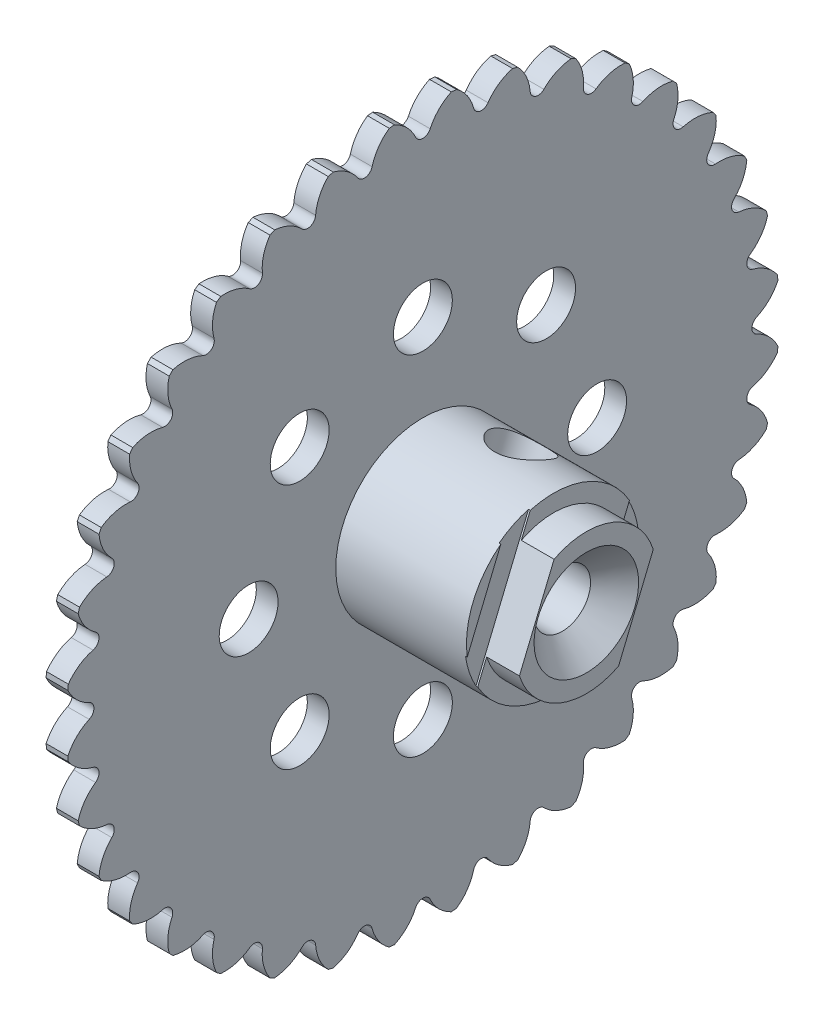
from build123d import *

# Parameters (mm, degrees)
SKETCH1_R           = 25.9588
BOSS_EXTRUDE1_DEPTH = 1.5875
SKETCH2_R           = 2.1463
CUT_EXTRUDE1_DEPTH  = 1.5875
CIRPATTERN1_COUNT   = 8
CUT_EXTRUDE2_DEPTH  = 1.5875
CIRPATTERN2_COUNT   = 36
SKETCH7_R           = 6.35
BOSS_EXTRUDE3_DEPTH = 9.525
BOSS_EXTRUDE4_DEPTH = 2.3876
SKETCH9_R           = 2.0574
CUT_EXTRUDE3_DEPTH  = 14.5001
CUT_EXTRUDE4_DEPTH  = 0.127
SKETCH12_W          = 1.984375
SKETCH12_H          = 12.7


with BuildPart() as part:
    # Sketch1 → Boss-Extrude1 (new body)
    with BuildSketch(Plane(origin=(0, 0, 0), x_dir=(0, 0, -1), z_dir=(1, 0, 0))):
        Circle(SKETCH1_R)
    extrude(amount=BOSS_EXTRUDE1_DEPTH)

    # Sketch2 → Cut-Extrude1 (cut)
    with BuildSketch(Plane(origin=(1.5875, 0, 0), x_dir=(0, 0, -1), z_dir=(1, 0, 0))):
        with Locations((0, 12.7)):
            Circle(SKETCH2_R)
    cut_extrude1 = extrude(amount=-CUT_EXTRUDE1_DEPTH, mode=Mode.SUBTRACT)

    # CirPattern1: Cut-Extrude1 ×8 about axis
    cirpattern1_axis = Axis((0, 0, 0), (1, 0, 0))
    for i in range(1, CIRPATTERN1_COUNT):
        add(cut_extrude1.rotate(cirpattern1_axis, i * 360 / CIRPATTERN1_COUNT), mode=Mode.SUBTRACT)

    # Sketch4 → Cut-Extrude2 (cut)
    with BuildSketch(Plane(origin=(1.5875, 0, 0), x_dir=(0, 0, -1), z_dir=(1, 0, 0))):
        with BuildLine():
            ThreePointArc((2.072622482, 25.875925751), (0, 25.9588), (-2.072622482, 25.875925751))
            ThreePointArc((-2.072622482, 25.875925751), (-1.163537989, 25.234699648), (-0.531460116, 24.319230865))
            ThreePointArc((-0.531460116, 24.319230865), (0, 23.9776), (0.531460116, 24.319230865))
            ThreePointArc((0.531460116, 24.319230865), (1.163537989, 25.234699648), (2.072622482, 25.875925751))
        make_face()
    cut_extrude2 = extrude(amount=-CUT_EXTRUDE2_DEPTH, mode=Mode.SUBTRACT)

    # CirPattern2: Cut-Extrude2 ×36 about axis
    cirpattern2_axis = Axis((0, 0, 0), (1, 0, 0))
    for i in range(1, CIRPATTERN2_COUNT):
        add(cut_extrude2.rotate(cirpattern2_axis, i * 360 / CIRPATTERN2_COUNT), mode=Mode.SUBTRACT)

    # Sketch7 → Boss-Extrude3 (add)
    with BuildSketch(Plane(origin=(1.5875, 0, 0), x_dir=(0, 0, -1), z_dir=(1, 0, 0))):
        Circle(SKETCH7_R)
    extrude(amount=BOSS_EXTRUDE3_DEPTH)

    # Sketch8 → Boss-Extrude4 (add)
    with BuildSketch(Plane(origin=(11.1125, 0, 0), x_dir=(0, 0, -1), z_dir=(1, 0, 0))):
        with BuildLine():
            Line((-4.876953722, -1.552504431), (-2.350740637, 4.546313459))
            ThreePointArc((-2.350740637, 4.546313459), (1.958612075, 4.728507835), (4.876953722, 1.552504431))
            Line((4.876953722, 1.552504431), (2.350740637, -4.546313459))
            ThreePointArc((2.350740637, -4.546313459), (-1.958612075, -4.728507835), (-4.876953722, -1.552504431))
        make_face()
    extrude(amount=BOSS_EXTRUDE4_DEPTH)

    # Sketch9 → Cut-Extrude3 (cut, through all)
    with BuildSketch(Plane(origin=(13.5001, 0, 0), x_dir=(0, 0, -1), z_dir=(1, 0, 0))):
        Circle(SKETCH9_R)
    extrude(amount=-CUT_EXTRUDE3_DEPTH, mode=Mode.SUBTRACT)

    # Sketch10 → Cut-Extrude4 (cut)
    with BuildSketch(Plane(origin=(11.1125, 0, 0), x_dir=(0, 0, -1), z_dir=(1, 0, 0))):
        with BuildLine():
            Line((-5.528101678, -3.124514657), (-1.699592681, 6.118323685))
            ThreePointArc((-1.699592681, 6.118323685), (-2.823102406, 5.687933966), (-3.845267539, 5.053357058))
            Line((-3.845267539, 5.053357058), (-6.292277796, -0.854248291))
            ThreePointArc((-6.292277796, -0.854248291), (-6.018211534, -2.025741823), (-5.528101678, -3.124514657))
        make_face()
        with BuildLine():
            Line((3.845267539, -5.053357058), (6.292277796, 0.854248291))
            ThreePointArc((6.292277796, 0.854248291), (6.018211534, 2.025741823), (5.528101678, 3.124514657))
            Line((5.528101678, 3.124514657), (1.699592681, -6.118323685))
            ThreePointArc((1.699592681, -6.118323685), (2.823102406, -5.687933966), (3.845267539, -5.053357058))
        make_face()
    extrude(amount=-CUT_EXTRUDE4_DEPTH, mode=Mode.SUBTRACT)

    # Sketch11 one side → Cut-Revolve4 (revolve, cut)
    with BuildSketch(Plane.XY):
        Polygon((9.6901, 0), (13.5001, -3.81), (13.5001, 0), align=None)
    revolve(axis=Axis((13.5001, 0, 0), (-1, 0, 0)), mode=Mode.SUBTRACT)

    # Sketch12 → Cut-Revolve5 (revolve, cut)
    with BuildSketch(Plane(origin=(0, 0, 0), x_dir=(-1, 0, 0), z_dir=(0, -0.382683432, -0.923879533))):
        with Locations((-7.3421875, 0)):
            Rectangle(SKETCH12_W, SKETCH12_H)
    revolve(axis=Axis((6.35, -5.866635031, 2.430039796), (0, 0.923879533, -0.382683432)), mode=Mode.SUBTRACT)


solid = part.part
